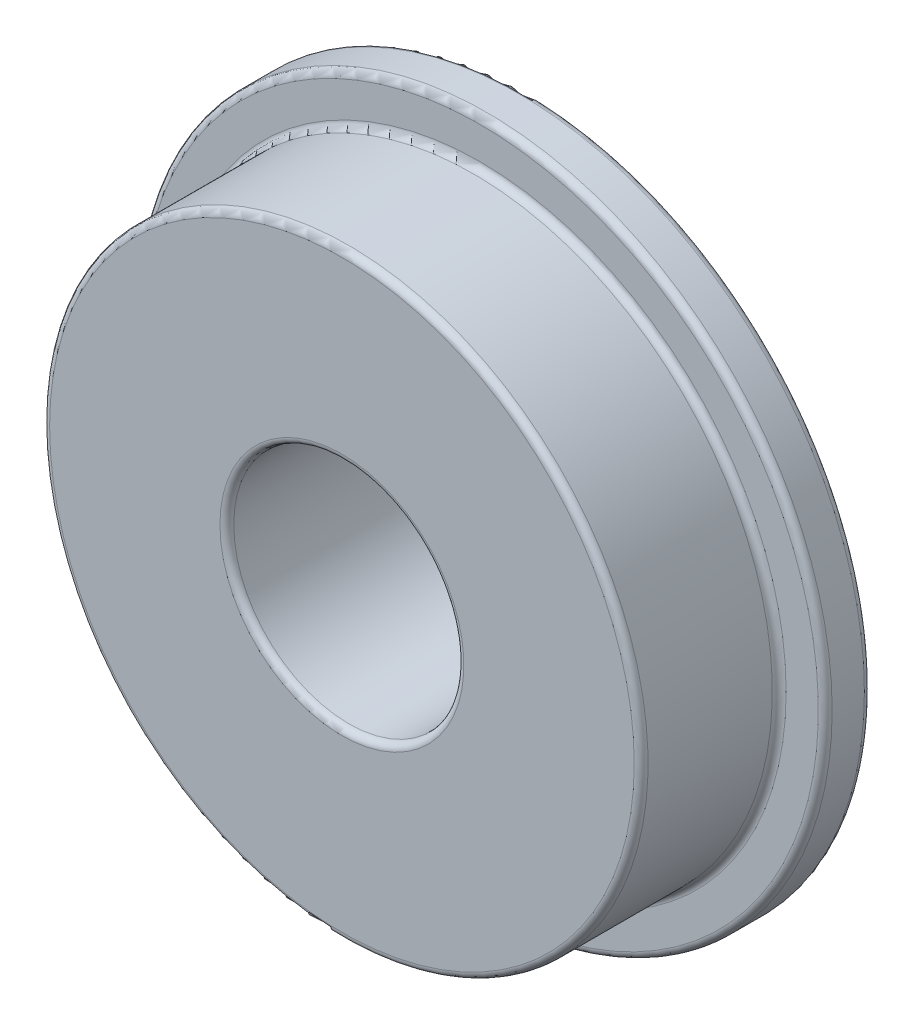
from build123d import *


with BuildPart() as part:
    # Sketch1 → Revolve1 (revolve)
    with BuildSketch(Plane(origin=(0, 0, 0), x_dir=(0, 0, -1), z_dir=(1, 0, 0))):
        with BuildLine():
            Line((4, 2.65), (4, 7.35))
            ThreePointArc((4, 7.35), (3.956066017, 7.456066017), (3.85, 7.5))
            Line((3.85, 7.5), (3.15, 7.5))
            ThreePointArc((3.15, 7.5), (3.043933983, 7.456066017), (3, 7.35))
            Line((3, 7.35), (3, 6.65))
            ThreePointArc((3, 6.65), (2.956066017, 6.543933983), (2.85, 6.5))
            Line((2.85, 6.5), (0.15, 6.5))
            ThreePointArc((0.15, 6.5), (0.043933983, 6.456066017), (0, 6.35))
            Line((0, 6.35), (0, 2.65))
            ThreePointArc((0, 2.65), (0.043933983, 2.543933983), (0.15, 2.5))
            Line((0.15, 2.5), (3.85, 2.5))
            ThreePointArc((3.85, 2.5), (3.956066017, 2.543933983), (4, 2.65))
        make_face()
    revolve(axis=Axis((0, 0, 0), (0, 0, 1)))


solid = part.part
